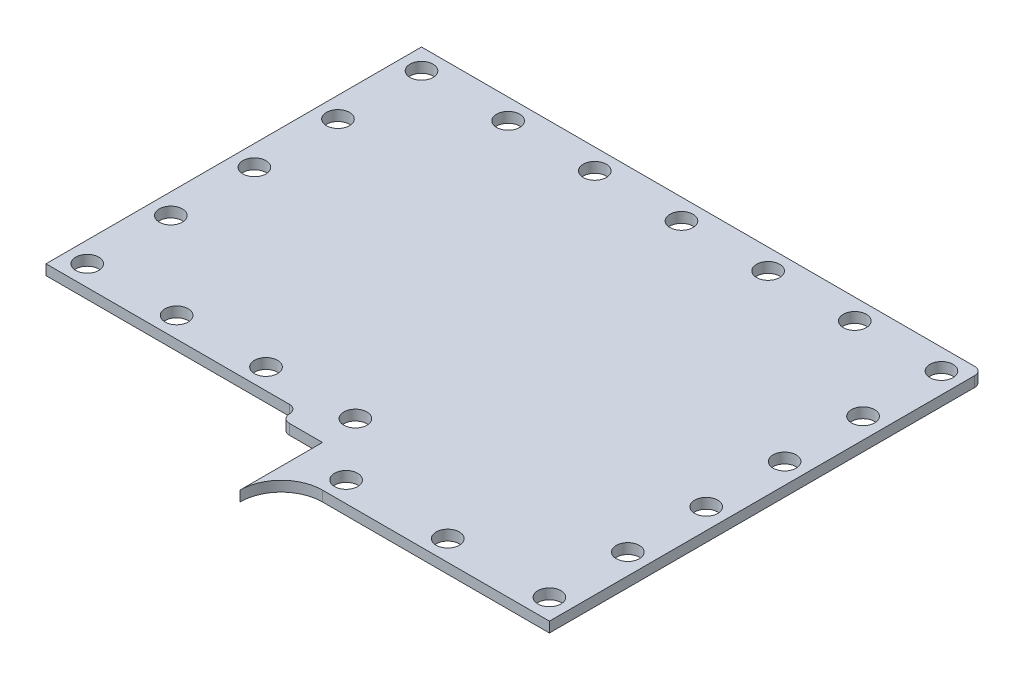
from build123d import *

# Parameters (mm, degrees)
BOSS_EXTRUDE1_DEPTH     = 1.5875
SKETCH2_R               = 1.778
CUT_EXTRUDE1_DEPTH      = 1
CUT_EXTRUDE1_DEPTH_BACK = 2.5875


with BuildPart() as part:
    # Sketch1 → Boss-Extrude1 (new body)
    with BuildSketch(Plane(origin=(0, 0, 0), x_dir=(1, 0, 0), z_dir=(0, 1, 0))):
        with BuildLine():
            Line((8.89, -66.675), (43.815, -66.675))
            Line((43.815, -66.675), (43.815, -1.27))
            ThreePointArc((43.815, -1.27), (43.453523156, -0.361476844), (42.545, 0))
            Line((42.545, 0), (-42.545, 0))
            Line((-42.545, 0), (-42.545, -57.785))
            Line((-42.545, -57.785), (-5.08, -57.785))
            ThreePointArc((-5.08, -57.785), (-4.181974388, -58.156974388), (-3.81, -59.055))
            ThreePointArc((-3.81, -59.055), (-3.438025612, -59.953025612), (-2.54, -60.325))
            Line((-2.54, -60.325), (2.54, -60.325))
            Line((2.54, -60.325), (2.54, -73.025))
            ThreePointArc((2.54, -73.025), (4.399871939, -68.534871939), (8.89, -66.675))
        make_face()
    extrude(amount=BOSS_EXTRUDE1_DEPTH)

    # Sketch2 → Cut-Extrude1 (cut, two sides)
    with BuildSketch(Plane(origin=(0, 1.5875, 0), x_dir=(-1, 0, 0), z_dir=(0, 1, 0))) as cut_extrude1_sk:
        with Locations((39.37, 3.175)):
            Circle(SKETCH2_R)
        with Locations((26.035, 3.175)):
            Circle(SKETCH2_R)
        with Locations((12.7, 3.175)):
            Circle(SKETCH2_R)
        with Locations((-0.635, 3.175)):
            Circle(SKETCH2_R)
        with Locations((-13.97, 3.175)):
            Circle(SKETCH2_R)
        with Locations((-27.305, 3.175)):
            Circle(SKETCH2_R)
        with Locations((-40.64, 3.175)):
            Circle(SKETCH2_R)
        with Locations((39.37, 16.03375)):
            Circle(SKETCH2_R)
        with Locations((39.37, 28.8925)):
            Circle(SKETCH2_R)
        with Locations((39.37, 41.75125)):
            Circle(SKETCH2_R)
        with Locations((-40.64, 15.24)):
            Circle(SKETCH2_R)
        with Locations((-40.64, 27.305)):
            Circle(SKETCH2_R)
        with Locations((-40.64, 39.37)):
            Circle(SKETCH2_R)
        with Locations((-40.64, 51.435)):
            Circle(SKETCH2_R)
        with Locations((-40.64, 63.5)):
            Circle(SKETCH2_R)
        with Locations((-24.994404736, 63.5)):
            Circle(SKETCH2_R)
        with Locations((-9.348809473, 63.5)):
            Circle(SKETCH2_R)
        with Locations((-1.889213751, 54.61)):
            Circle(SKETCH2_R)
        with Locations((11.863857499, 54.61)):
            Circle(SKETCH2_R)
        with Locations((25.61692875, 54.61)):
            Circle(SKETCH2_R)
        with Locations((39.37, 54.61)):
            Circle(SKETCH2_R)
    extrude(amount=CUT_EXTRUDE1_DEPTH, mode=Mode.SUBTRACT)
    extrude(cut_extrude1_sk.sketch, amount=-CUT_EXTRUDE1_DEPTH_BACK, mode=Mode.SUBTRACT)


solid = part.part
